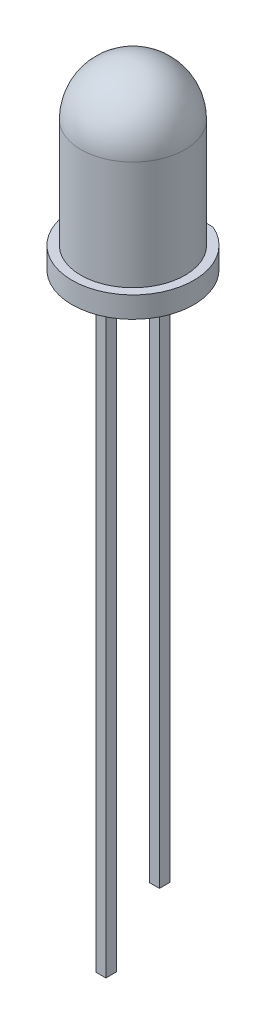
from build123d import *

# Parameters (mm, degrees)
EXTRUDE_1_DEPTH = 1
SKETCH_2_R      = 2.46
EXTRUDE_2_DEPTH = 7.6
SKETCH_4_W      = 0.47
SKETCH_4_H      = 0.5
EXTRUDE_3_DEPTH = 25.7
SKETCH_5_W      = 0.47
SKETCH_5_H      = 0.5
EXTRUDE_4_DEPTH = 2.4


with BuildPart() as part:
    # 草图1 → 凸台-拉伸1 (new body)
    with BuildSketch(Plane(origin=(0, 0, 0), x_dir=(1, 0, 0), z_dir=(0, 1, 0))):
        with BuildLine():
            Line((-1.149957, 2.635), (1.149957, 2.635))
            ThreePointArc((1.149957, 2.635), (0, -2.875), (-1.149957, 2.635))
        make_face()
    extrude(amount=EXTRUDE_1_DEPTH)

    # 草图2 → 凸台-拉伸2 (add)
    with BuildSketch(Plane(origin=(0, 1, 0), x_dir=(1, 0, 0), z_dir=(0, 1, 0))):
        Circle(SKETCH_2_R)
    extrude(amount=EXTRUDE_2_DEPTH)

    # 草图3 → 切除-旋转1 (revolve, cut)
    with BuildSketch(Plane(origin=(0, 0, 0), x_dir=(0, 0, -1), z_dir=(1, 0, 0))):
        with BuildLine():
            Line((-2.46, 6.14), (-4.608425, 6.14))
            Line((-4.608425, 6.14), (-4.608425, 10.205518))
            Line((-4.608425, 10.205518), (0, 10.205518))
            Line((0, 10.205518), (0, 8.6))
            ThreePointArc((0, 8.6), (-1.739483, 7.879483), (-2.46, 6.14))
        make_face()
    revolve(axis=Axis((0, 10.969013, 0), (0, -1, 0)), mode=Mode.SUBTRACT)

    # 草图4 → 凸台-拉伸3 (add)
    with BuildSketch(Plane.XZ):
        with Locations((0, -1.265)):
            Rectangle(SKETCH_4_W, SKETCH_4_H)
        with Locations((0, 1.265)):
            Rectangle(SKETCH_4_W, SKETCH_4_H)
    extrude(amount=EXTRUDE_3_DEPTH)

    # 草图5 → 凸台-拉伸4 (add)
    with BuildSketch(Plane.XZ.offset(25.7)):
        with Locations((0, 1.265)):
            Rectangle(SKETCH_5_W, SKETCH_5_H)
    extrude(amount=EXTRUDE_4_DEPTH)


solid = part.part
